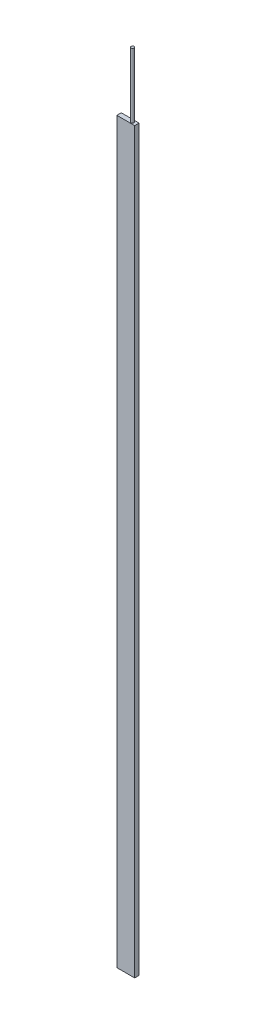
from build123d import *

# Parameters (mm, degrees)
SKETCH1_W           = 138.0236
SKETCH1_H           = 34.1122
BOSS_EXTRUDE1_DEPTH = 5710
SKETCH2_R           = 11.43
BOSS_EXTRUDE2_DEPTH = 500


with BuildPart() as part:
    # Sketch1 → Boss-Extrude1 (new body)
    with BuildSketch(Plane(origin=(0, 0, 0), x_dir=(1, 0, 0), z_dir=(0, 1, 0))):
        Rectangle(SKETCH1_W, SKETCH1_H)
    extrude(amount=BOSS_EXTRUDE1_DEPTH)

    # Sketch2 → Boss-Extrude2 (add)
    with BuildSketch(Plane(origin=(0, 5710, 0), x_dir=(1, 0, 0), z_dir=(0, 1, 0))):
        with Locations((35.4584, 0)):
            Circle(SKETCH2_R)
    extrude(amount=BOSS_EXTRUDE2_DEPTH)


solid = part.part
